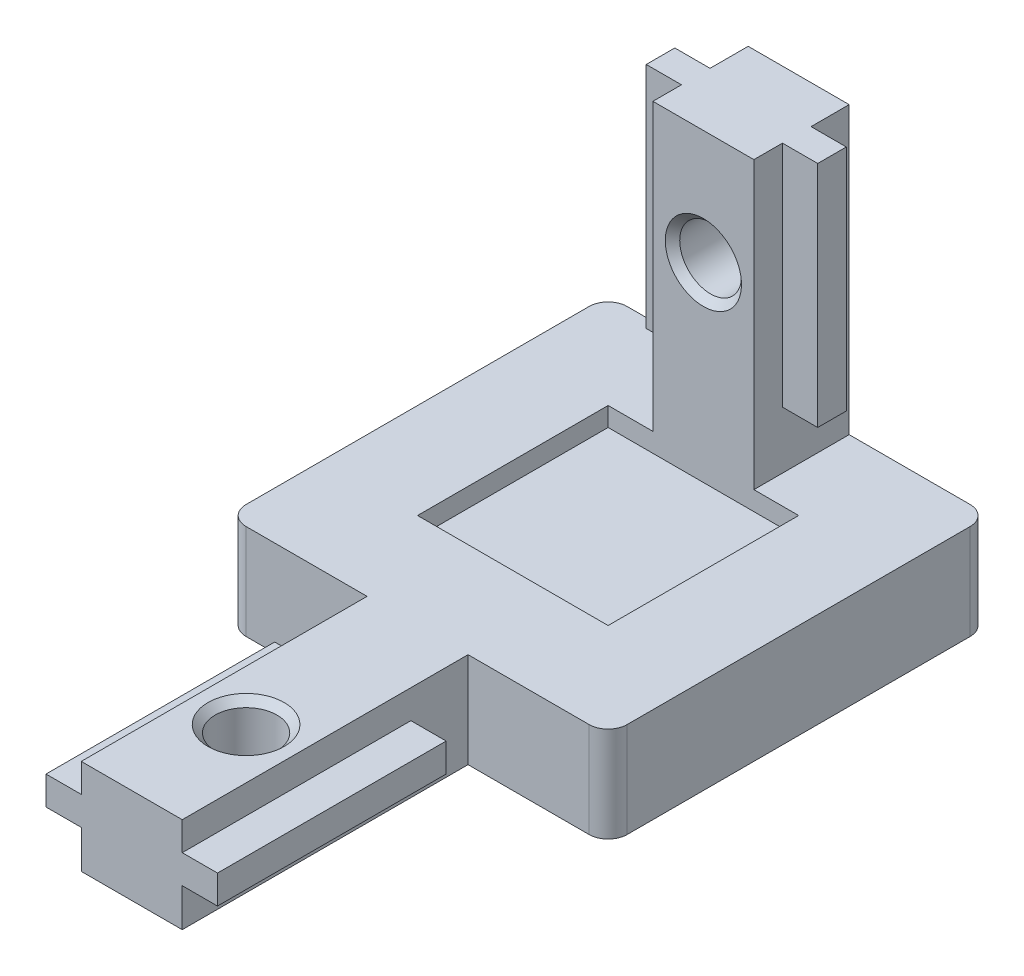
from build123d import *

# Parameters (mm, degrees)
SKETCH1_W                = 20
SKETCH1_H                = 35
BOSS_EXTRUDE1_DEPTH      = 5
SKETCH2_W                = 5.3
SKETCH2_H                = 5
BOSS_EXTRUDE2_DEPTH      = 15
SKETCH3_W                = 10
SKETCH3_H                = 10
CUT_EXTRUDE1_DEPTH       = 1
SKETCH4_W                = 7.35
SKETCH4_H                = 15
CUT_EXTRUDE2_DEPTH       = 21
SKETCH5_W                = 7.35
SKETCH5_H                = 15
CUT_EXTRUDE3_DEPTH       = 21
SKETCH6_W                = 1.5
SKETCH6_H                = 12
BOSS_EXTRUDE3_DEPTH      = 1.85
SKETCH7_W                = 1.5
SKETCH7_H                = 12
BOSS_EXTRUDE4_DEPTH      = 1.85
SKETCH8_W                = 12
SKETCH8_H                = 1.5
BOSS_EXTRUDE5_DEPTH      = 1.85
SKETCH9_W                = 12
SKETCH9_H                = 1.5
BOSS_EXTRUDE6_DEPTH      = 1.85
M3_CLEARANCE_HOLE1_D     = 3.242
M3_CLEARANCE_HOLE1_DEPTH = 20.000025
M3_CLEARANCE_HOLE2_D     = 3.242
M3_CLEARANCE_HOLE2_DEPTH = 5.00005
CHAMFER1_SIZE            = 0.379
FILLET1_R                = 1


with BuildPart() as part:
    # Sketch1 → Boss-Extrude1 (new body)
    with BuildSketch(Plane(origin=(0, 5, 0), x_dir=(1, 0, 0), z_dir=(0, 1, 0))):
        with Locations((0, -17.5)):
            Rectangle(SKETCH1_W, SKETCH1_H)
    extrude(amount=-BOSS_EXTRUDE1_DEPTH)

    # Sketch2 → Boss-Extrude2 (add)
    with BuildSketch(Plane(origin=(0, 5, 0), x_dir=(-1, 0, 0), z_dir=(0, 1, 0))):
        with Locations((0, 2.5)):
            Rectangle(SKETCH2_W, SKETCH2_H)
    extrude(amount=BOSS_EXTRUDE2_DEPTH)

    # Sketch3 → Cut-Extrude1 (cut)
    with BuildSketch(Plane(origin=(0, 5, 0), x_dir=(-1, 0, 0), z_dir=(0, 1, 0))):
        with Locations((0, 10)):
            Rectangle(SKETCH3_W, SKETCH3_H)
    extrude(amount=-CUT_EXTRUDE1_DEPTH, mode=Mode.SUBTRACT)

    # Sketch4 → Cut-Extrude2 (cut, through all)
    with BuildSketch(Plane.XZ):
        with Locations((-6.325, 27.5)):
            Rectangle(SKETCH4_W, SKETCH4_H)
    extrude(amount=-CUT_EXTRUDE2_DEPTH, mode=Mode.SUBTRACT)

    # Sketch5 → Cut-Extrude3 (cut, through all)
    with BuildSketch(Plane.XZ):
        with Locations((6.325, 27.5)):
            Rectangle(SKETCH5_W, SKETCH5_H)
    extrude(amount=-CUT_EXTRUDE3_DEPTH, mode=Mode.SUBTRACT)

    # Sketch6 → Boss-Extrude3 (add)
    with BuildSketch(Plane(origin=(2.65, 0, 0), x_dir=(0, 0, -1), z_dir=(1, 0, 0))):
        with Locations((-2.75, 14)):
            Rectangle(SKETCH6_W, SKETCH6_H)
    extrude(amount=BOSS_EXTRUDE3_DEPTH)

    # Sketch7 → Boss-Extrude4 (add)
    with BuildSketch(Plane.ZY.offset(2.65)):
        with Locations((2.75, 14)):
            Rectangle(SKETCH7_W, SKETCH7_H)
    extrude(amount=BOSS_EXTRUDE4_DEPTH)

    # Sketch8 → Boss-Extrude5 (add)
    with BuildSketch(Plane.ZY.offset(2.65)):
        with Locations((29, 2.75)):
            Rectangle(SKETCH8_W, SKETCH8_H)
    extrude(amount=BOSS_EXTRUDE5_DEPTH)

    # Sketch9 → Boss-Extrude6 (add)
    with BuildSketch(Plane(origin=(2.65, 0, 0), x_dir=(0, 0, -1), z_dir=(1, 0, 0))):
        with Locations((-29, 2.75)):
            Rectangle(SKETCH9_W, SKETCH9_H)
    extrude(amount=BOSS_EXTRUDE6_DEPTH)

    # M3 Clearance Hole1
    with Locations(Plane(origin=(0, 0, 0), x_dir=(-1, 0, 0), z_dir=(0, -1, 0))):
        with Locations((0, -29)):
            Hole(M3_CLEARANCE_HOLE1_D / 2, depth=M3_CLEARANCE_HOLE1_DEPTH)

    # M3 Clearance Hole2
    with Locations(Plane.XY.offset(5)):
        with Locations((0, 14)):
            Hole(M3_CLEARANCE_HOLE2_D / 2, depth=M3_CLEARANCE_HOLE2_DEPTH)

    # Chamfer1
    chamfer1_edges = [part.edges().sort_by_distance(p)[0] for p in [
        (-1.621, 5, 29),
        (-1.621, 0, 29),
        (1.621, 14, 0),
        (1.621, 14, 5),
    ]]
    chamfer(chamfer1_edges, length=CHAMFER1_SIZE)

    # Fillet1
    fillet1_edges = [part.edges().sort_by_distance(p)[0] for p in [
        (-10, 2.5, 20),
        (10, 2.5, 0),
        (10, 2.5, 20),
        (-10, 2.5, 0),
    ]]
    fillet(fillet1_edges, radius=FILLET1_R)


solid = part.part
